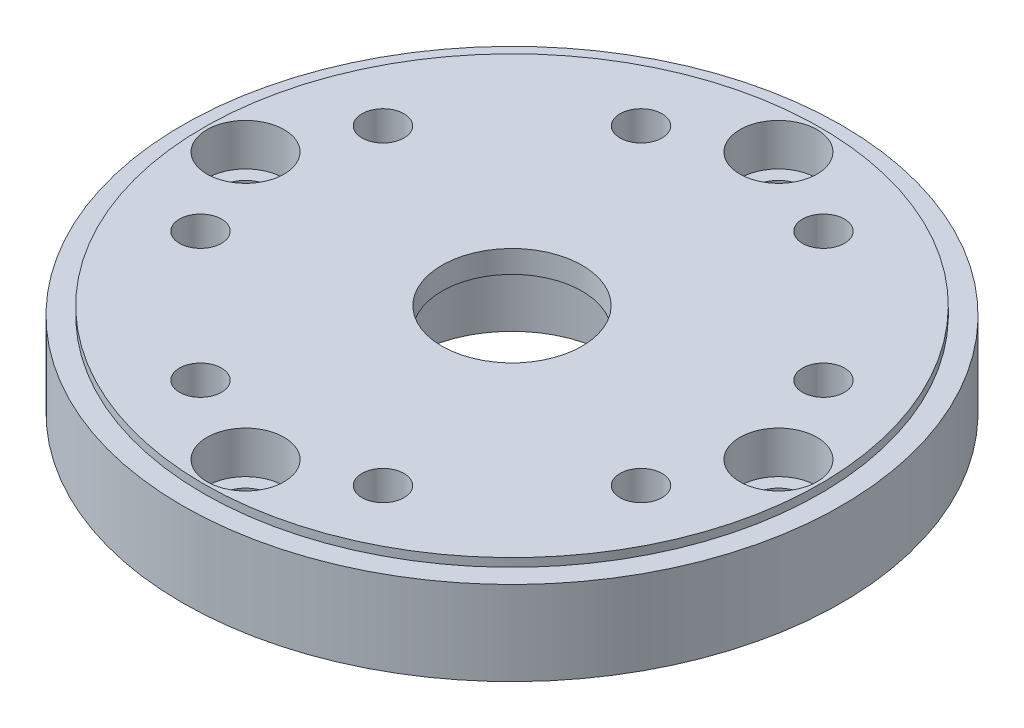
from build123d import *

# Parameters (mm, degrees)
SKETCH1_R                = 23.5
SKETCH1_R_2              = 7.1
BOSS_EXTRUDE1_DEPTH      = 6
SKETCH2_R                = 22
SKETCH2_R_2              = 5
BOSS_EXTRUDE2_DEPTH      = 0.6
BOSS_EXTRUDE2_DEPTH_BACK = 1
SKETCH3_R                = 1.75
CUT_EXTRUDE1_DEPTH       = 7.6
CUT_EXTRUDE2_START       = -6.6
SKETCH4_R                = 2.75
SKETCH4_R_2              = 1.75
CUT_EXTRUDE2_DEPTH       = 3
SKETCH5_R                = 1.5
CUT_EXTRUDE3_DEPTH       = 7.6


with BuildPart() as part:
    # Sketch1 → Boss-Extrude1 (new body)
    with BuildSketch(Plane(origin=(0, 0, 0), x_dir=(1, 0, 0), z_dir=(0, 1, 0))):
        Circle(SKETCH1_R)
        Circle(SKETCH1_R_2, mode=Mode.SUBTRACT)
    extrude(amount=BOSS_EXTRUDE1_DEPTH)

    # Sketch2 → Boss-Extrude2 (add, two sides)
    with BuildSketch(Plane(origin=(0, 6, 0), x_dir=(1, 0, 0), z_dir=(0, 1, 0))) as boss_extrude2_sk:
        Circle(SKETCH2_R)
        Circle(SKETCH2_R_2, mode=Mode.SUBTRACT)
    extrude(amount=BOSS_EXTRUDE2_DEPTH)
    extrude(boss_extrude2_sk.sketch, amount=-BOSS_EXTRUDE2_DEPTH_BACK)

    # Sketch3 → Cut-Extrude1 (cut, through all)
    with BuildSketch(Plane.XZ):
        with Locations((0, 19)):
            Circle(SKETCH3_R)
        with Locations((19, 0)):
            Circle(SKETCH3_R)
        with Locations((0, -19)):
            Circle(SKETCH3_R)
        with Locations((-19, 0)):
            Circle(SKETCH3_R)
    extrude(amount=-CUT_EXTRUDE1_DEPTH, mode=Mode.SUBTRACT)

    # Sketch4 → Cut-Extrude2 (cut)
    with BuildSketch(Plane(origin=(0, 0, 0), x_dir=(-1, 0, 0), z_dir=(0, -1, 0)).offset(CUT_EXTRUDE2_START)):
        with Locations((0, 19)):
            Circle(SKETCH4_R)
        with Locations((0, 19)):
            Circle(SKETCH4_R_2, mode=Mode.SUBTRACT)
        with Locations((19, 0)):
            Circle(SKETCH4_R)
        with Locations((19, 0)):
            Circle(SKETCH4_R_2, mode=Mode.SUBTRACT)
        with Locations((-19, 0)):
            Circle(SKETCH4_R)
        with Locations((-19, 0)):
            Circle(SKETCH4_R_2, mode=Mode.SUBTRACT)
        with Locations((0, -19)):
            Circle(SKETCH4_R)
        with Locations((0, -19)):
            Circle(SKETCH4_R_2, mode=Mode.SUBTRACT)
    extrude(amount=CUT_EXTRUDE2_DEPTH, mode=Mode.SUBTRACT)

    # Sketch5 → Cut-Extrude3 (cut, through all)
    with BuildSketch(Plane(origin=(0, 6.6, 0), x_dir=(1, 0, 0), z_dir=(0, 1, 0))):
        with Locations((-6.50561835, 15.705952053)):
            Circle(SKETCH5_R)
        with Locations((6.50561835, 15.705952053)):
            Circle(SKETCH5_R)
        with Locations((15.705952053, 6.50561835)):
            Circle(SKETCH5_R)
        with Locations((15.705952053, -6.50561835)):
            Circle(SKETCH5_R)
        with Locations((6.50561835, -15.705952053)):
            Circle(SKETCH5_R)
        with Locations((-6.50561835, -15.705952053)):
            Circle(SKETCH5_R)
        with Locations((-15.705952053, -6.50561835)):
            Circle(SKETCH5_R)
        with Locations((-15.705952053, 6.50561835)):
            Circle(SKETCH5_R)
    extrude(amount=-CUT_EXTRUDE3_DEPTH, mode=Mode.SUBTRACT)


solid = part.part
